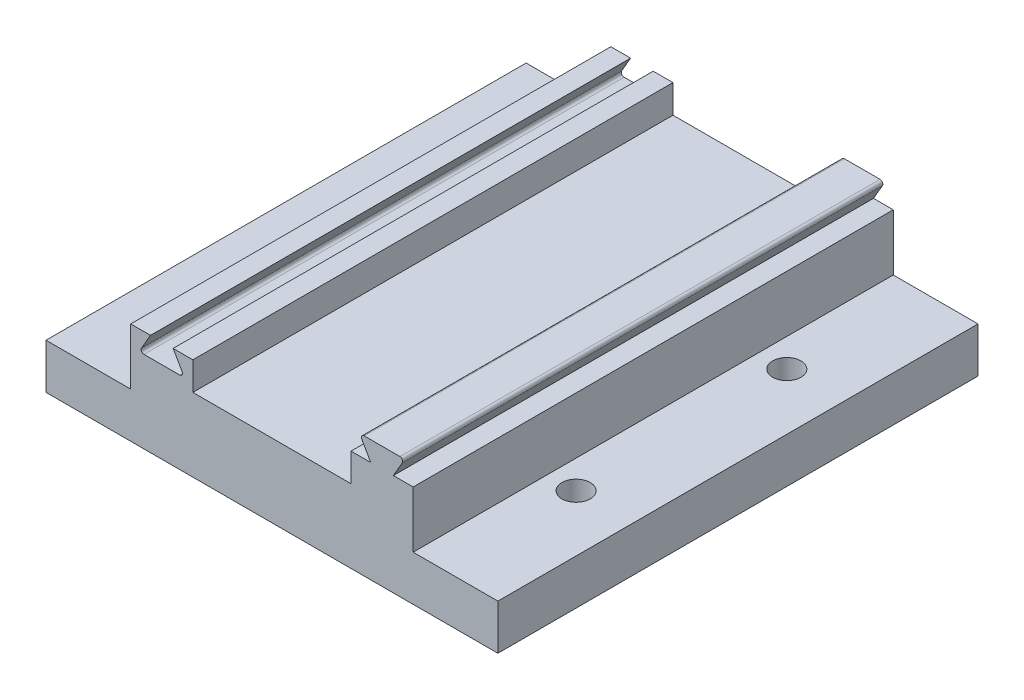
from build123d import *

# Parameters (mm, degrees)
SKETCH7_W           = 50
SKETCH7_H           = 85
BOSS_EXTRUDE5_DEPTH = 10
SKETCH8_W           = 28
SKETCH8_H           = 85
CUT_EXTRUDE1_DEPTH  = 5
SKETCH11_W          = 11
SKETCH11_H          = 85
BOSS_EXTRUDE6_DEPTH = 3.5
CUT_EXTRUDE5_DEPTH  = 86
CUT_EXTRUDE6_DEPTH  = 86
SKETCH14_W          = 50
SKETCH14_H          = 85
SKETCH14_W_2        = 15
BOSS_EXTRUDE7_DEPTH = 8
CUT_EXTRUDE11_DEPTH = 2
SKETCH19_R          = 2.510624494
CUT_EXTRUDE12_DEPTH = 20.5


with BuildPart() as part:
    # Sketch7 → Boss-Extrude5 (new body)
    with BuildSketch(Plane(origin=(0, 0, 0), x_dir=(1, 0, 0), z_dir=(0, 1, 0))):
        Rectangle(SKETCH7_W, SKETCH7_H)
    extrude(amount=BOSS_EXTRUDE5_DEPTH)

    # Sketch8 → Cut-Extrude1 (cut)
    with BuildSketch(Plane(origin=(0, 10, 0), x_dir=(1, 0, 0), z_dir=(0, 1, 0))):
        Rectangle(SKETCH8_W, SKETCH8_H)
    extrude(amount=-CUT_EXTRUDE1_DEPTH, mode=Mode.SUBTRACT)

    # Sketch11 → Boss-Extrude6 (add)
    with BuildSketch(Plane(origin=(0, 10, 0), x_dir=(1, 0, 0), z_dir=(0, 1, 0))):
        with Locations((19.5, 0)):
            Rectangle(SKETCH11_W, SKETCH11_H)
    extrude(amount=BOSS_EXTRUDE6_DEPTH)

    # Sketch12 → Cut-Extrude5 (cut, through all)
    with BuildSketch(Plane.XY.offset(42.5)):
        with BuildLine():
            Line((-21.5, 10), (-17.5, 10))
            Line((-17.5, 10), (-15.91228676, 7.25))
            ThreePointArc((-15.91228676, 7.25), (-15.91228676, 6.75), (-16.345299462, 6.5))
            Line((-16.345299462, 6.5), (-22.654700538, 6.5))
            ThreePointArc((-22.654700538, 6.5), (-23.08771324, 6.75), (-23.08771324, 7.25))
            Line((-23.08771324, 7.25), (-21.5, 10))
        make_face()
    extrude(amount=-CUT_EXTRUDE5_DEPTH, mode=Mode.SUBTRACT)

    # Sketch13 → Cut-Extrude6 (cut, through all)
    with BuildSketch(Plane.XY.offset(42.5)):
        with BuildLine():
            Line((21.5, 10), (25, 10))
            Line((25, 10), (25, 13.5))
            Line((25, 13.5), (22.654700538, 13.5))
            ThreePointArc((22.654700538, 13.5), (23.08771324, 13.25), (23.08771324, 12.75))
            Line((23.08771324, 12.75), (21.5, 10))
        make_face()
        with BuildLine():
            Line((14, 10), (17.5, 10))
            Line((17.5, 10), (15.91228676, 12.75))
            ThreePointArc((15.91228676, 12.75), (15.91228676, 13.25), (16.345299462, 13.5))
            Line((16.345299462, 13.5), (14, 13.5))
            Line((14, 13.5), (14, 10))
        make_face()
    extrude(amount=-CUT_EXTRUDE6_DEPTH, mode=Mode.SUBTRACT)

    # Sketch14 → Boss-Extrude7 (add)
    with BuildSketch(Plane.XZ):
        Rectangle(SKETCH14_W, SKETCH14_H)
        with Locations((32.5, 0)):
            Rectangle(SKETCH14_W_2, SKETCH14_H)
        with Locations((-32.5, 0)):
            Rectangle(SKETCH14_W_2, SKETCH14_H)
    extrude(amount=BOSS_EXTRUDE7_DEPTH)

    # Sketch18 → Cut-Extrude11 (cut)
    with BuildSketch(Plane.XZ.offset(8)):
        with BuildLine():
            Line((30.5, -23.25), (-30.5, -23.25))
            ThreePointArc((-30.5, -23.25), (-33.399137803, -22.049137803), (-34.6, -19.15))
            Line((-34.6, -19.15), (-34.6, 19.15))
            ThreePointArc((-34.6, 19.15), (-33.399137803, 22.049137803), (-30.5, 23.25))
            Line((-30.5, 23.25), (30.5, 23.25))
            ThreePointArc((30.5, 23.25), (33.399137803, 22.049137803), (34.6, 19.15))
            Line((34.6, 19.15), (34.6, -19.15))
            ThreePointArc((34.6, -19.15), (33.399137803, -22.049137803), (30.5, -23.25))
        make_face()
    extrude(amount=-CUT_EXTRUDE11_DEPTH, mode=Mode.SUBTRACT)

    # Sketch19 → Cut-Extrude12 (cut, through all)
    with BuildSketch(Plane.XZ.offset(6)):
        with Locations((-30, 18.65)):
            Circle(SKETCH19_R)
        with Locations((-30, -18.65)):
            Circle(SKETCH19_R)
        with Locations((30, -18.65)):
            Circle(SKETCH19_R)
        with Locations((30, 18.65)):
            Circle(SKETCH19_R)
    extrude(amount=-CUT_EXTRUDE12_DEPTH, mode=Mode.SUBTRACT)


solid = part.part
